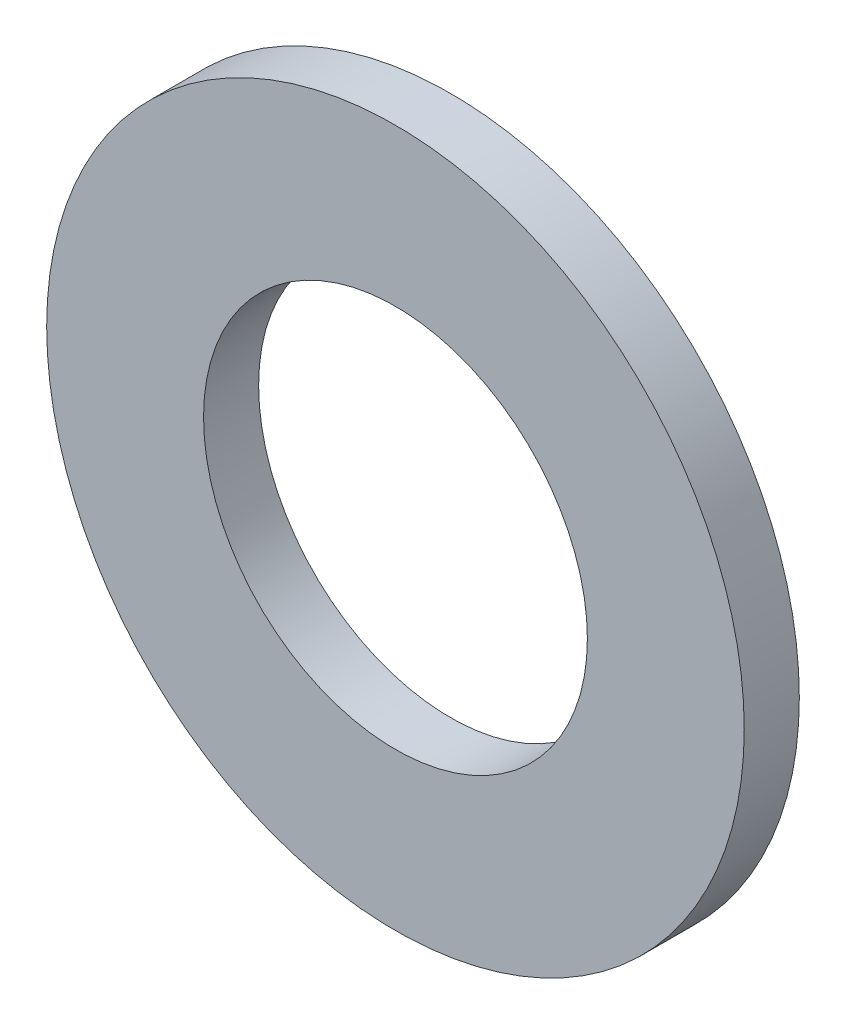
from build123d import *

# Parameters (mm, degrees)
SKETCH3_R           = 2.6543
SKETCH3_R_2         = 1.4605
BOSS_EXTRUDE1_DEPTH = 0.20955


with BuildPart() as part:
    # Sketch3 → Boss-Extrude1 (new, symmetric)
    with BuildSketch(Plane.XY):
        Circle(SKETCH3_R)
        Circle(SKETCH3_R_2, mode=Mode.SUBTRACT)
    extrude(amount=BOSS_EXTRUDE1_DEPTH, both=True)


solid = part.part
